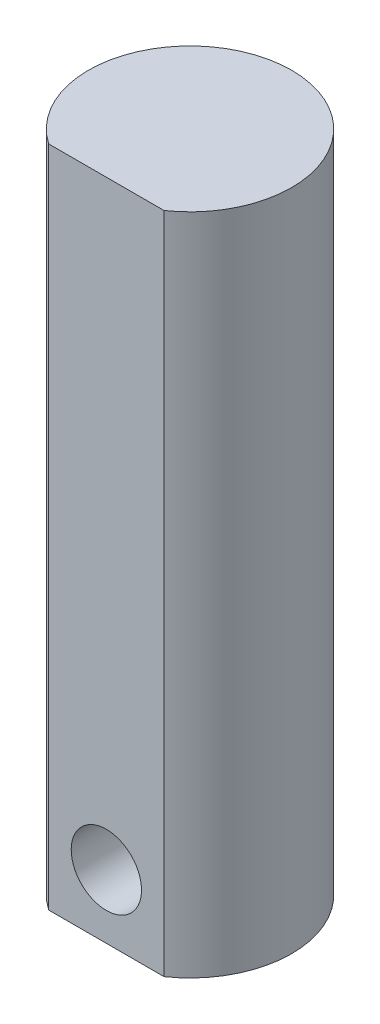
from build123d import *

# Parameters (mm, degrees)
BOSS_EXTRU_1_DEPTH      = 23.585
ENL_V_START             = 5.949002
ESQUISSE4_OUTSIDE_W     = 26.662
ESQUISSE4_OUTSIDE_H     = 59.382
ESQUISSE4_OUTSIDE_W_2   = 228.2
ESQUISSE4_OUTSIDE_H_2   = 267.17
ESQUISSE4_OUTSIDE_R     = 2.5
ENL_V_MAT_EXTRU_5_DEPTH = 3.75


with BuildPart() as part:
    # Esquisse2 → Boss.-Extru.1 (new body, symmetric)
    with BuildSketch(Plane(origin=(0, 0, 0), x_dir=(1, 0, 0), z_dir=(0, 1, 0))):
        with BuildLine():
            Line((-4.1, -5.949002017), (4.1, -5.949002017))
            ThreePointArc((4.1, -5.949002017), (0, 7.225), (-4.1, -5.949002017))
        make_face()
    extrude(amount=BOSS_EXTRU_1_DEPTH, both=True)

    # Esquisse4 outside → Enlèv. mat.-Extru.5 (cut)
    with BuildSketch(Plane.XY.offset(ENL_V_START)):
        Rectangle(ESQUISSE4_OUTSIDE_W, ESQUISSE4_OUTSIDE_H)
        Rectangle(ESQUISSE4_OUTSIDE_W_2, ESQUISSE4_OUTSIDE_H_2, mode=Mode.SUBTRACT)
        with Locations(Location((0, -19.06, 0), (0, 0, 180))):  # turned: the seam where the file's is
            Circle(ESQUISSE4_OUTSIDE_R)
    extrude(amount=-ENL_V_MAT_EXTRU_5_DEPTH, mode=Mode.SUBTRACT)


solid = part.part
